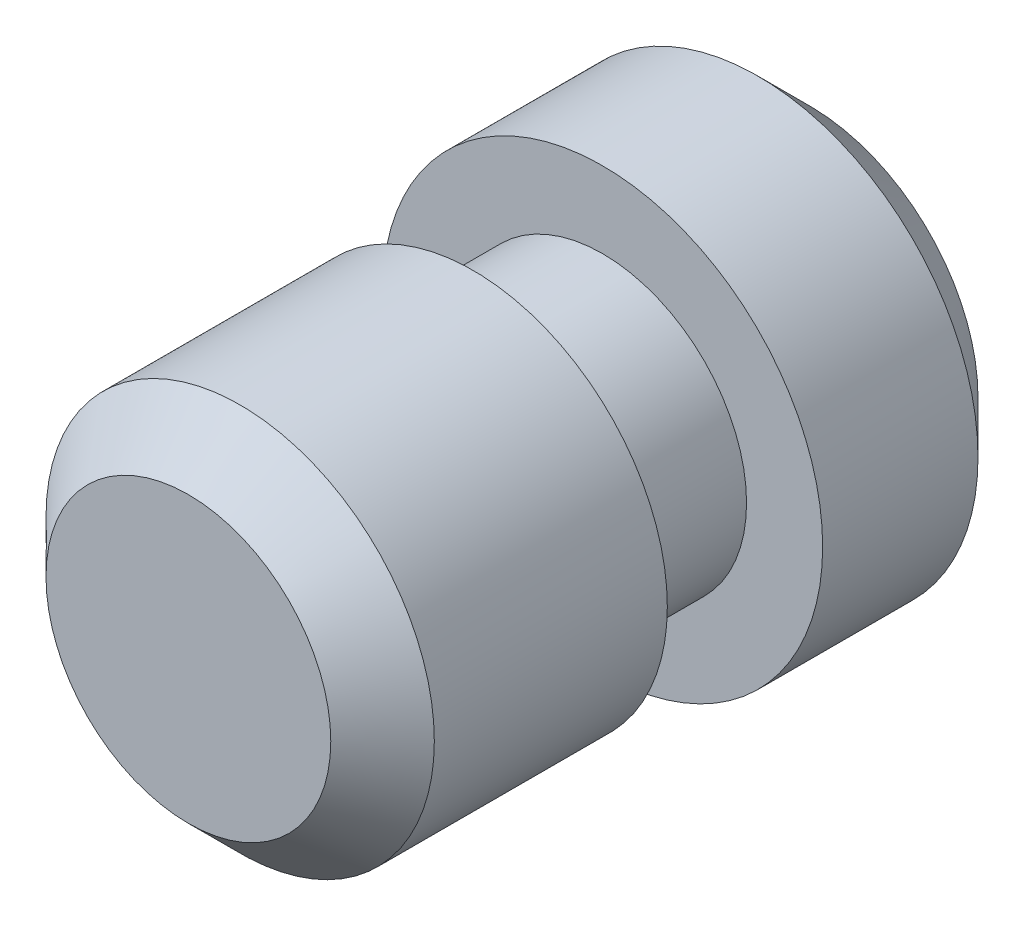
from build123d import *

# Parameters (mm, degrees)
SKETCH1_R           = 5.3975
BOSS_EXTRUDE1_DEPTH = 5.08
SKETCH3_R           = 3.5306
BOSS_EXTRUDE2_DEPTH = 3.175
SKETCH4_R           = 4.7625
BOSS_EXTRUDE3_DEPTH = 6.985
CHAMFER1_SIZE       = 1.27
CHAMFER2_SIZE       = 1.27


with BuildPart() as part:
    # Sketch1 → Boss-Extrude1 (new body)
    with BuildSketch(Plane.XY):
        Circle(SKETCH1_R)
    extrude(amount=BOSS_EXTRUDE1_DEPTH)

    # Sketch3 → Boss-Extrude2 (add)
    with BuildSketch(Plane.XY.offset(5.08)):
        Circle(SKETCH3_R)
    extrude(amount=BOSS_EXTRUDE2_DEPTH)

    # Sketch4 → Boss-Extrude3 (add)
    with BuildSketch(Plane.XY.offset(8.255)):
        Circle(SKETCH4_R)
    extrude(amount=BOSS_EXTRUDE3_DEPTH)

    # Chamfer1
    chamfer1_edges = [part.edges().sort_by_distance(p)[0] for p in [
        (-4.7625, 0, 15.24),
    ]]
    chamfer(chamfer1_edges, length=CHAMFER1_SIZE)

    # Chamfer2
    chamfer2_edges = [part.edges().sort_by_distance(p)[0] for p in [
        (-5.3975, 0, 0),
    ]]
    chamfer(chamfer2_edges, length=CHAMFER2_SIZE)


solid = part.part
